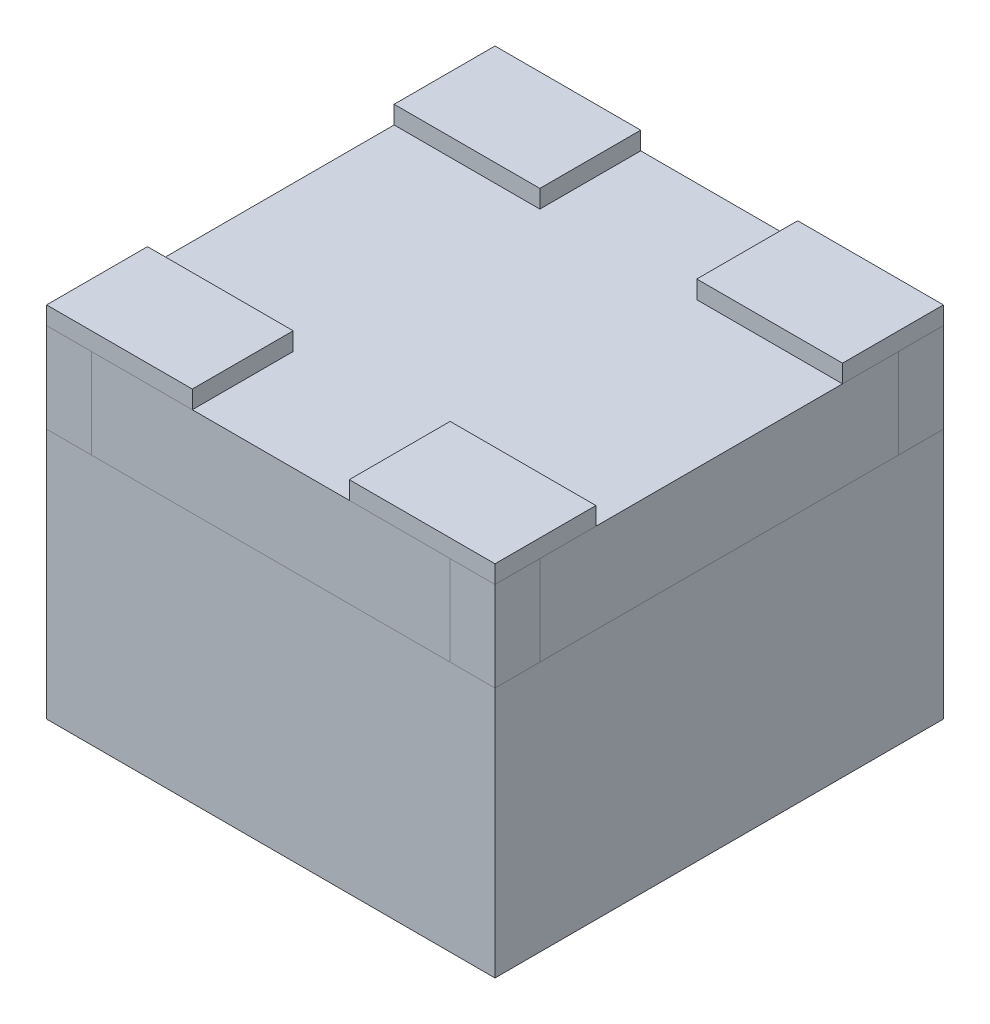
from build123d import *

# Parameters (mm, degrees)
SKETCH_1_W          = 1
SKETCH_1_H          = 1
EXTRUDE_1_DEPTH     = 0.2
SKETCH_3_W          = 0.325
SKETCH_3_H          = 0.225
EXTRUDE_2_DEPTH     = 0.04
EXTRUDE_2_2_DEPTH   = 0.04
EXTRUDE_2_3_DEPTH   = 0.04
EXTRUDE_2_4_DEPTH   = 0.04
SKETCH_4_W          = 0.4
SKETCH_4_H          = 1
EXTRUDE_3_DEPTH     = 0.04
SKETCH_4_W_2        = 0.325
EXTRUDE_3_2_DEPTH   = 0.04
SKETCH_5_W          = 0.35
SKETCH_5_H          = 0.4
EXTRUDE_4_DEPTH     = 0.05
SKETCH_7_W          = 0.1
SKETCH_7_H          = 0.1
EXTRUDE_5_DEPTH     = 0.05
EXTRUDE_5_2_DEPTH   = 0.05
SKETCH_7_H_2        = 0.2
EXTRUDE_5_3_DEPTH   = 0.05
SKETCH_8_W          = 1
SKETCH_8_H          = 1
EXTRUDE_6_DEPTH     = 0.56
SKETCH_12_W         = 0.1
SKETCH_12_H         = 0.2
CUT_EXTRUDE_1_DEPTH = 0.1
SKETCH_11_W         = 0.1
SKETCH_11_H         = 0.2
CUT_EXTRUDE_2_DEPTH = 0.1
SKETCH_16_W         = 0.1
SKETCH_16_H         = 0.2
CUT_EXTRUDE_3_DEPTH = 0.1
SKETCH_18_W         = 0.1
SKETCH_18_H         = 0.2
EXTRUDE_7_DEPTH     = 0.1
SKETCH_19_W         = 0.1
SKETCH_19_H         = 0.2
EXTRUDE_8_DEPTH     = 0.1
SKETCH_20_W         = 0.1
SKETCH_20_H         = 0.2
EXTRUDE_9_DEPTH     = 0.1
SKETCH_21_W         = 0.1
SKETCH_21_H         = 0.2
EXTRUDE_10_DEPTH    = 0.1


with BuildPart() as part:
    # 草图1 → 凸台-拉伸1 (new body)
    with BuildSketch(Plane(origin=(0, 0, 0), x_dir=(1, 0, 0), z_dir=(0, 1, 0))):
        with Locations((-0.449579832, 0.260504202)):
            Rectangle(SKETCH_1_W, SKETCH_1_H)
    extrude(amount=EXTRUDE_1_DEPTH)

    # 草图12 → 切除-拉伸1 (cut)
    with BuildSketch(Plane.ZY.offset(0.949579832)):
        with Locations((0.189495798, 0.1)):
            Rectangle(SKETCH_12_W, SKETCH_12_H)
    extrude(amount=-CUT_EXTRUDE_1_DEPTH, mode=Mode.SUBTRACT)

    # 草图11 → 切除-拉伸2 (cut)
    with BuildSketch(Plane.ZY.offset(0.949579832)):
        with Locations((-0.710504202, 0.1)):
            Rectangle(SKETCH_11_W, SKETCH_11_H)
    extrude(amount=-CUT_EXTRUDE_2_DEPTH, mode=Mode.SUBTRACT)

    # 草图16 → 切除-拉伸3 (cut)
    with BuildSketch(Plane(origin=(0.050420168, 0, 0), x_dir=(0, 0, -1), z_dir=(1, 0, 0))):
        with Locations((-0.189495798, 0.1)):
            Rectangle(SKETCH_16_W, SKETCH_16_H)
        with Locations((0.710504202, 0.1)):
            Rectangle(SKETCH_16_W, SKETCH_16_H)
    extrude(amount=-CUT_EXTRUDE_3_DEPTH, mode=Mode.SUBTRACT)


with BuildPart() as body_2:
    # 草图3 → 凸台-拉伸2 (new body)
    with BuildSketch(Plane(origin=(0, 0.2, 0), x_dir=(1, 0, 0), z_dir=(0, 1, 0))):
        with Locations((-0.787079832, 0.648004202)):
            Rectangle(SKETCH_3_W, SKETCH_3_H)
    extrude(amount=EXTRUDE_2_DEPTH)


with BuildPart() as body_3:
    # 草图3 → Extrude 2 2 (new body)
    with BuildSketch(Plane(origin=(0, 0.2, 0), x_dir=(1, 0, 0), z_dir=(0, 1, 0))):
        with Locations((-0.112079832, 0.648004202)):
            Rectangle(SKETCH_3_W, SKETCH_3_H)
    extrude(amount=EXTRUDE_2_2_DEPTH)


with BuildPart() as body_4:
    # 草图3 → Extrude 2 3 (new body)
    with BuildSketch(Plane(origin=(0, 0.2, 0), x_dir=(1, 0, 0), z_dir=(0, 1, 0))):
        with Locations((-0.787079832, -0.126995798)):
            Rectangle(SKETCH_3_W, SKETCH_3_H)
    extrude(amount=EXTRUDE_2_3_DEPTH)


with BuildPart() as body_5:
    # 草图3 → Extrude 2 4 (new body)
    with BuildSketch(Plane(origin=(0, 0.2, 0), x_dir=(1, 0, 0), z_dir=(0, 1, 0))):
        with Locations((-0.112079832, -0.126995798)):
            Rectangle(SKETCH_3_W, SKETCH_3_H)
    extrude(amount=EXTRUDE_2_4_DEPTH)


with BuildPart() as body_6:
    # 草图4 → 凸台-拉伸3 (new body)
    with BuildSketch(Plane.XZ):
        with Locations((-0.749579832, -0.260504202)):
            Rectangle(SKETCH_4_W, SKETCH_4_H)
    extrude(amount=EXTRUDE_3_DEPTH)


with BuildPart() as body_7:
    # 草图4 → Extrude 3 2 (new body)
    with BuildSketch(Plane.XZ):
        with Locations((-0.112079832, -0.260504202)):
            Rectangle(SKETCH_4_W_2, SKETCH_4_H)
    extrude(amount=EXTRUDE_3_2_DEPTH)


with BuildPart() as body_8:
    # 草图5 → 凸台-拉伸4 (new body)
    with BuildSketch(Plane.XZ.offset(0.04)):
        with Locations((-0.749579832, -0.260504202)):
            Rectangle(SKETCH_5_W, SKETCH_5_H)
    extrude(amount=EXTRUDE_4_DEPTH)


with BuildPart() as body_9:
    # 草图7 → 凸台-拉伸5 (new body)
    with BuildSketch(Plane.XZ.offset(0.04)):
        with Locations((-0.114579832, -0.060504202)):
            Rectangle(SKETCH_7_W, SKETCH_7_H)
    extrude(amount=EXTRUDE_5_DEPTH)


with BuildPart() as body_10:
    # 草图7 → Extrude 5 2 (new body)
    with BuildSketch(Plane.XZ.offset(0.04)):
        with Locations((-0.114579832, -0.460504202)):
            Rectangle(SKETCH_7_W, SKETCH_7_H)
    extrude(amount=EXTRUDE_5_2_DEPTH)


with BuildPart() as body_11:
    # 草图7 → Extrude 5 3 (new body)
    with BuildSketch(Plane.XZ.offset(0.04)):
        with Locations((-0.114579832, -0.260504202)):
            Rectangle(SKETCH_7_W, SKETCH_7_H_2)
    extrude(amount=EXTRUDE_5_3_DEPTH)


with BuildPart() as body_12:
    # 草图8 → 凸台-拉伸6 (new body)
    with BuildSketch(Plane.XZ):
        with Locations((-0.449579832, -0.260504202)):
            Rectangle(SKETCH_8_W, SKETCH_8_H)
    extrude(amount=EXTRUDE_6_DEPTH)


with BuildPart() as body_13:
    # 草图18 → 凸台-拉伸7 (new body)
    with BuildSketch(Plane(origin=(-0.049579832, 0, 0), x_dir=(0, 0, -1), z_dir=(1, 0, 0))):
        with Locations((-0.189495798, 0.1)):
            Rectangle(SKETCH_18_W, SKETCH_18_H)
    extrude(amount=EXTRUDE_7_DEPTH)


with BuildPart() as body_14:
    # 草图19 → 凸台-拉伸8 (new body)
    with BuildSketch(Plane(origin=(-0.049579832, 0, 0), x_dir=(0, 0, -1), z_dir=(1, 0, 0))):
        with Locations((0.710504202, 0.1)):
            Rectangle(SKETCH_19_W, SKETCH_19_H)
    extrude(amount=EXTRUDE_8_DEPTH)


with BuildPart() as body_15:
    # 草图20 → 凸台-拉伸9 (new body)
    with BuildSketch(Plane.ZY.offset(0.849579832)):
        with Locations((0.189495798, 0.1)):
            Rectangle(SKETCH_20_W, SKETCH_20_H)
    extrude(amount=EXTRUDE_9_DEPTH)


with BuildPart() as body_16:
    # 草图21 → 凸台-拉伸10 (new body)
    with BuildSketch(Plane.ZY.offset(0.849579832)):
        with Locations((-0.710504202, 0.1)):
            Rectangle(SKETCH_21_W, SKETCH_21_H)
    extrude(amount=EXTRUDE_10_DEPTH)


solid = Compound([part.part, body_2.part, body_3.part, body_4.part, body_5.part, body_6.part, body_7.part, body_8.part, body_9.part, body_10.part, body_11.part, body_12.part, body_13.part, body_14.part, body_15.part, body_16.part])
